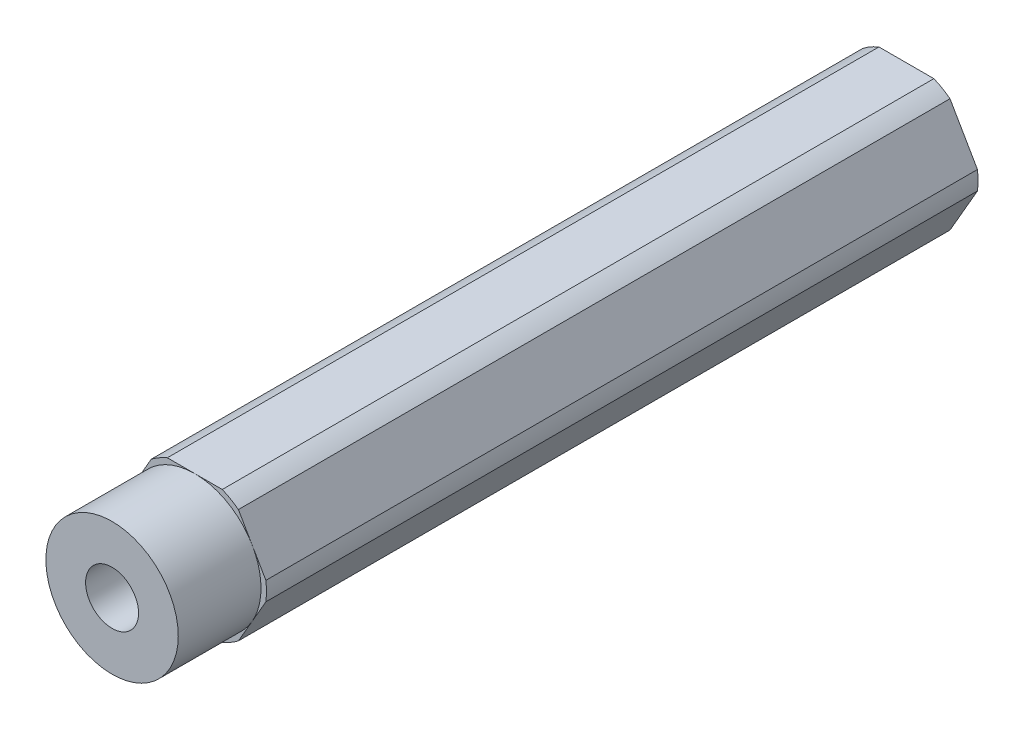
from build123d import *

# Parameters (mm, degrees)
SKETCH1_R           = 2.54
BOSS_EXTRUDE1_DEPTH = 76.2
SKETCH2_OUTSIDE_W   = 31.444
SKETCH2_OUTSIDE_H   = 30.394
SKETCH2_OUTSIDE_R   = 6.35
CUT_EXTRUDE1_DEPTH  = 7.9375


with BuildPart() as part:
    # Sketch1 → Boss-Extrude1 (new body)
    with BuildSketch(Plane.XY):
        with BuildLine():
            Line((4.181770802, -5.456960506), (6.816751826, -0.893039494))
            ThreePointArc((6.816751826, -0.893039494), (6.875, 0), (6.816751826, 0.893039494))
            Line((6.816751826, 0.893039494), (4.181770802, 5.456960506))
            ThreePointArc((4.181770802, 5.456960506), (3.4375, 5.953924651), (2.634981025, 6.35))
            Line((2.634981025, 6.35), (-2.634981025, 6.35))
            ThreePointArc((-2.634981025, 6.35), (-3.4375, 5.953924651), (-4.181770802, 5.456960506))
            Line((-4.181770802, 5.456960506), (-6.816751826, 0.893039494))
            ThreePointArc((-6.816751826, 0.893039494), (-6.875, 0), (-6.816751826, -0.893039494))
            Line((-6.816751826, -0.893039494), (-4.181770802, -5.456960506))
            ThreePointArc((-4.181770802, -5.456960506), (-3.4375, -5.953924651), (-2.634981025, -6.35))
            Line((-2.634981025, -6.35), (2.634981025, -6.35))
            ThreePointArc((2.634981025, -6.35), (3.4375, -5.953924651), (4.181770802, -5.456960506))
        make_face()
        Circle(SKETCH1_R, mode=Mode.SUBTRACT)
    extrude(amount=BOSS_EXTRUDE1_DEPTH)

    # Sketch2 outside → Cut-Extrude1 (cut)
    with BuildSketch(Plane.XY.offset(76.2)):
        Rectangle(SKETCH2_OUTSIDE_W, SKETCH2_OUTSIDE_H)
        Circle(SKETCH2_OUTSIDE_R, mode=Mode.SUBTRACT)
    extrude(amount=-CUT_EXTRUDE1_DEPTH, mode=Mode.SUBTRACT)


solid = part.part
